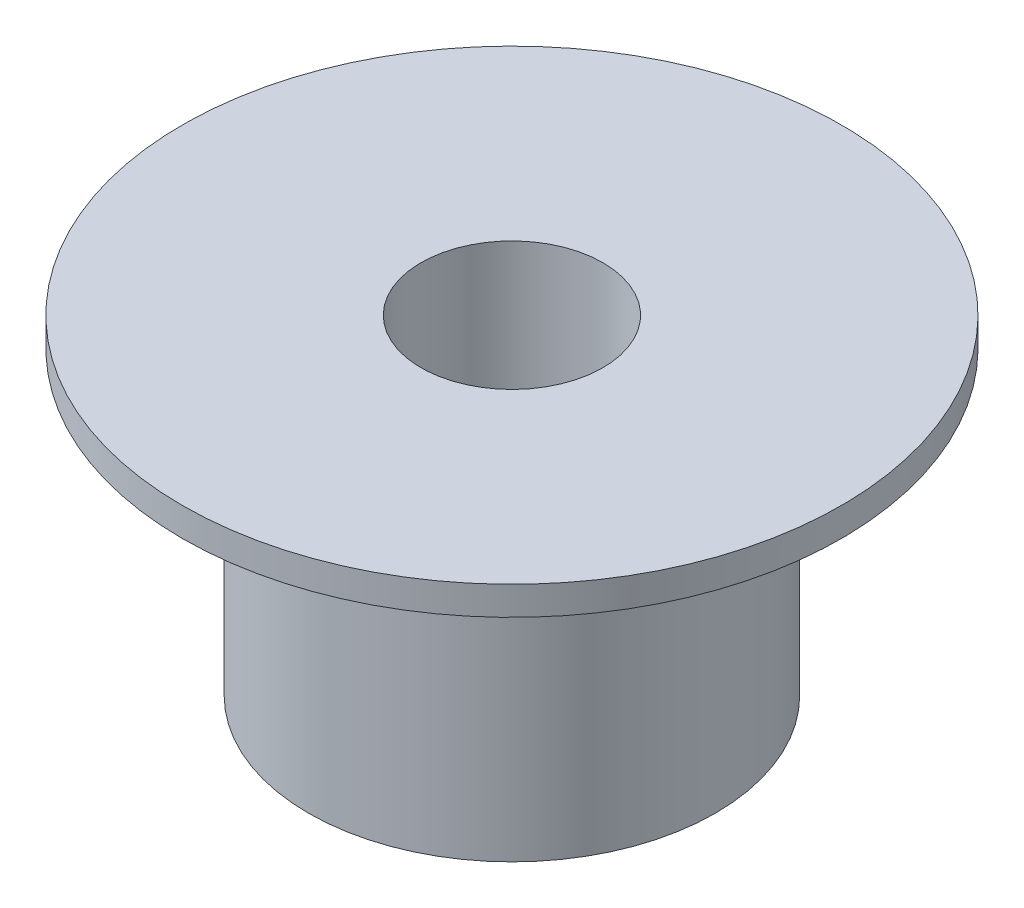
from build123d import *

# Parameters (mm, degrees)
SKETCH1_R           = 7.1
BOSS_EXTRUDE1_DEPTH = 10.5
SKETCH2_R           = 11.5
BOSS_EXTRUDE2_DEPTH = 1
SKETCH3_R           = 3.175
CUT_EXTRUDE1_DEPTH  = 12.5


with BuildPart() as part:
    # Sketch1 → Boss-Extrude1 (new body)
    with BuildSketch(Plane(origin=(0, 0, 0), x_dir=(1, 0, 0), z_dir=(0, 1, 0))):
        Circle(SKETCH1_R)
    extrude(amount=BOSS_EXTRUDE1_DEPTH)

    # Sketch2 → Boss-Extrude2 (add)
    with BuildSketch(Plane(origin=(0, 10.5, 0), x_dir=(1, 0, 0), z_dir=(0, 1, 0))):
        Circle(SKETCH2_R)
    extrude(amount=BOSS_EXTRUDE2_DEPTH)

    # Sketch3 → Cut-Extrude1 (cut, through all)
    with BuildSketch(Plane.XZ):
        Circle(SKETCH3_R)
    extrude(amount=-CUT_EXTRUDE1_DEPTH, mode=Mode.SUBTRACT)


solid = part.part
